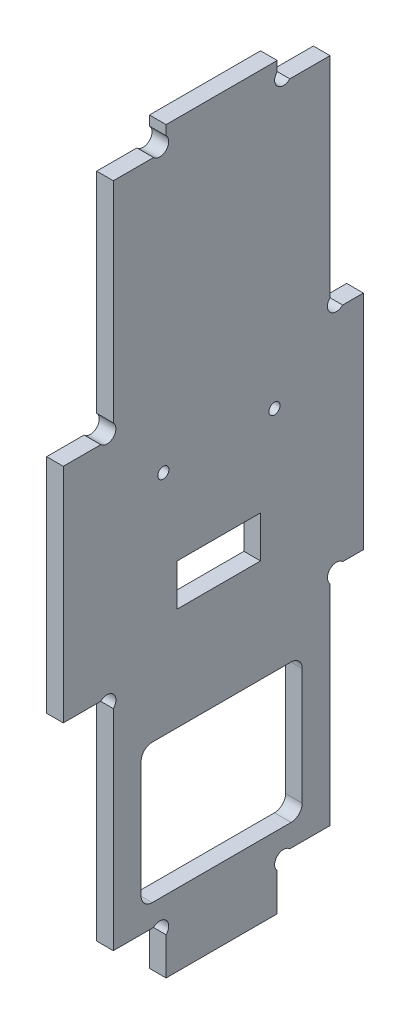
from build123d import *

# Parameters (mm, degrees)
EXTRUSION1_DEPTH        = 3
ESQUISSE2_R             = 1
ESQUISSE2_W             = 29
ESQUISSE2_H             = 25
ENL_V_MAT_EXTRU_1_DEPTH = 4
CONG_1_R                = 2
ESQUISSE3_W             = 15
ESQUISSE3_H             = 7.5
ENL_V_MAT_EXTRU_2_DEPTH = 4


with BuildPart() as part:
    # Esquisse1 → Extrusion1 (new body)
    with BuildSketch(Plane(origin=(0, 0, 0), x_dir=(0, 0, -1), z_dir=(1, 0, 0))):
        with BuildLine():
            Line((18.5, 6.7372583), (18.5, 0))
            Line((18.5, 0), (38.5, 0))
            Line((38.5, 0), (38.5, 6.7372583))
            ThreePointArc((38.5, 6.7372583), (38.5, 9), (40.7627417, 9))
            Line((40.7627417, 9), (48, 9))
            Line((48, 9), (48, 46.7372583))
            ThreePointArc((48, 46.7372583), (48, 49), (50.2627417, 49))
            Line((50.2627417, 49), (54, 49))
            Line((54, 49), (54, 89))
            Line((54, 89), (50.2627417, 89))
            ThreePointArc((50.2627417, 89), (48, 89), (48, 91.2627417))
            Line((48, 91.2627417), (48, 129))
            Line((48, 129), (40.7627417, 129))
            ThreePointArc((40.7627417, 129), (38.5, 129), (38.5, 131.2627417))
            Line((38.5, 131.2627417), (38.5, 133))
            Line((38.5, 133), (18.5, 133))
            Line((18.5, 133), (18.5, 131.2627417))
            ThreePointArc((18.5, 131.2627417), (18.5, 129), (16.2372583, 129))
            Line((16.2372583, 129), (9, 129))
            Line((9, 129), (9, 91.2627417))
            ThreePointArc((9, 91.2627417), (9, 89), (6.7372583, 89))
            Line((6.7372583, 89), (0, 89))
            Line((0, 89), (0, 49))
            Line((0, 49), (6.7372583, 49))
            ThreePointArc((6.7372583, 49), (9, 49), (9, 46.7372583))
            Line((9, 46.7372583), (9, 9))
            Line((9, 9), (16.2372583, 9))
            ThreePointArc((16.2372583, 9), (18.5, 9), (18.5, 6.7372583))
        make_face()
    extrude(amount=EXTRUSION1_DEPTH)

    # Esquisse2 → Enlèv. mat.-Extru.1 (cut, through all)
    with BuildSketch(Plane.ZY):
        with Locations((-38, 79)):
            Circle(ESQUISSE2_R)
        with Locations((-18, 79)):
            Circle(ESQUISSE2_R)
        with Locations((-28.5, 25.5)):
            Rectangle(ESQUISSE2_W, ESQUISSE2_H)
    extrude(amount=-ENL_V_MAT_EXTRU_1_DEPTH, mode=Mode.SUBTRACT)

    # Congé1
    cong_1_edges = [part.edges().sort_by_distance(p)[0] for p in [
        (1.5, 38, -14),
        (1.5, 13, -14),
        (1.5, 13, -43),
        (1.5, 38, -43),
    ]]
    fillet(cong_1_edges, radius=CONG_1_R)

    # Esquisse3 → Enlèv. mat.-Extru.2 (cut, through all)
    with BuildSketch(Plane.ZY):
        with Locations((-28, 60.25)):
            Rectangle(ESQUISSE3_W, ESQUISSE3_H)
    extrude(amount=-ENL_V_MAT_EXTRU_2_DEPTH, mode=Mode.SUBTRACT)


solid = part.part
